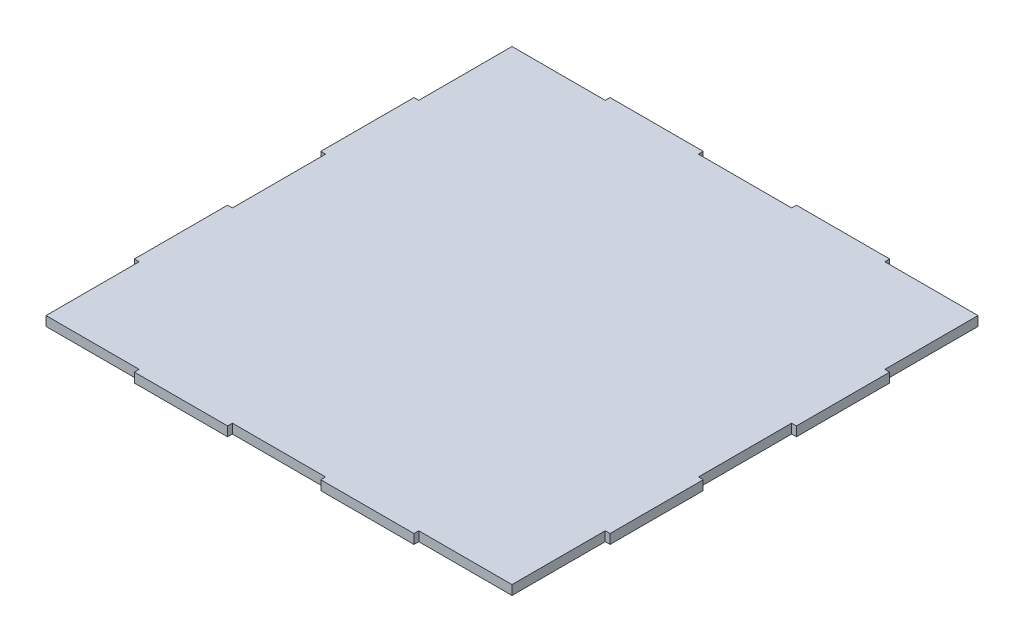
from build123d import *

# Parameters (mm, degrees)
BOSS_EXTRUDE1_DEPTH = 5.9944


with BuildPart() as part:
    # Sketch1 → Boss-Extrude1 (new body)
    with BuildSketch(Plane(origin=(0, 0, 0), x_dir=(1, 0, 0), z_dir=(0, 1, 0))):
        Polygon((0, 0), (59.0804, 0), (59.0804, -3.048), (118.1608, -3.048), (118.1608, 0), (177.2412, 0), (177.2412, -3.048), (236.3216, -3.048), (236.3216, 0), (295.402, 0), (295.402, 59.0804), (298.45, 59.0804), (298.45, 118.1608), (295.402, 118.1608), (295.402, 177.2412), (298.45, 177.2412), (298.45, 236.3216), (295.402, 236.3216), (295.402, 295.402), (236.3216, 295.402), (236.3216, 298.45), (177.2412, 298.45), (177.2412, 295.402), (118.1608, 295.402), (118.1608, 298.45), (59.0804, 298.45), (59.0804, 295.402), (0, 295.402), (0, 236.3216), (-3.048, 236.3216), (-3.048, 177.2412), (0, 177.2412), (0, 118.1608), (-3.048, 118.1608), (-3.048, 59.0804), (0, 59.0804), align=None)
    extrude(amount=BOSS_EXTRUDE1_DEPTH)


solid = part.part
